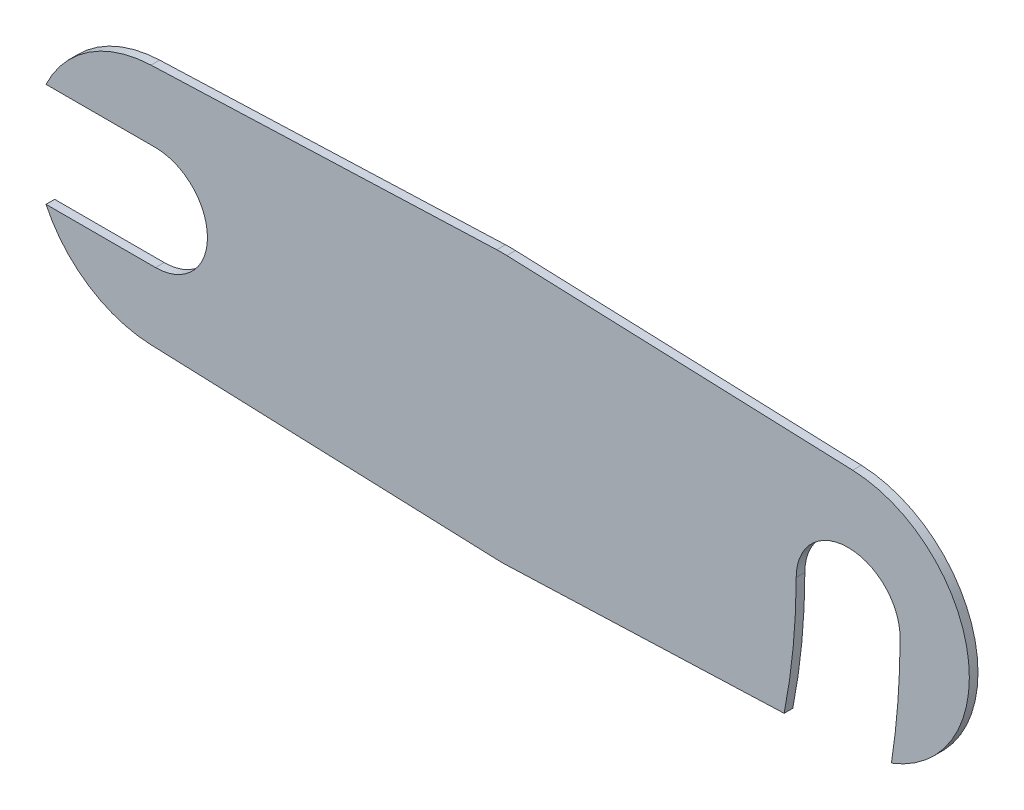
from build123d import *

# Parameters (mm, degrees)
SZKIC1_R                    = 3
DODANIE_WYCI_GNI_CIE1_DEPTH = 0.5
WYTNIJ_WYCI_GNI_CIE1_DEPTH  = 1.5
WYTNIJ_WYCI_GNI_CIE3_DEPTH  = 1.5


with BuildPart() as part:
    # Szkic1 → Dodanie-wyciągnięcie1 (new body)
    with BuildSketch(Plane.XY):
        with BuildLine():
            Line((-0.290625, 7.744548864), (-20.2625, 6.995076393))
            ThreePointArc((-20.2625, 6.995076393), (-27, 0), (-20.2625, -6.995076393))
            Line((-20.2625, -6.995076393), (-0.290625, -7.744548864))
            ThreePointArc((-0.290625, -7.744548864), (0, -7.75), (0.290625, -7.744548864))
            Line((0.290625, -7.744548864), (20.2625, -6.995076393))
            ThreePointArc((20.2625, -6.995076393), (27, 0), (20.2625, 6.995076393))
            Line((20.2625, 6.995076393), (0.290625, 7.744548864))
            ThreePointArc((0.290625, 7.744548864), (0, 7.75), (-0.290625, 7.744548864))
        make_face()
        with Locations((-20, 0)):
            Circle(SZKIC1_R, mode=Mode.SUBTRACT)
        with Locations((20, 0)):
            Circle(SZKIC1_R, mode=Mode.SUBTRACT)
    extrude(amount=DODANIE_WYCI_GNI_CIE1_DEPTH)

    # Szkic2 → Wytnij-wyciągnięcie1 (cut, through all)
    with BuildSketch(Plane.XY.offset(0.5)):
        with BuildLine():
            Line((-20, 3), (-26.32455532, 3))
            ThreePointArc((-26.32455532, 3), (-27, 0), (-26.32455532, -3))
            Line((-26.32455532, -3), (-20, -3))
            ThreePointArc((-20, -3), (-23, 0), (-20, 3))
        make_face()
    extrude(amount=-WYTNIJ_WYCI_GNI_CIE1_DEPTH, mode=Mode.SUBTRACT)

    # Szkic3 → Wytnij-wyciągnięcie3 (cut, through all)
    with BuildSketch(Plane.XY.offset(0.5)):
        with BuildLine():
            ThreePointArc((17, 0), (16.825547843, -3.588735998), (16.303836429, -7.143630766))
            Line((16.303836429, -7.143630766), (20.2625, -6.995076393))
            ThreePointArc((20.2625, -6.995076393), (21.400000598, -6.858571158), (22.5, -6.538348415))
            ThreePointArc((22.5, -6.538348415), (22.874817784, -3.278719262), (23, 0))
            ThreePointArc((23, 0), (20, -3), (17, 0))
        make_face()
    extrude(amount=-WYTNIJ_WYCI_GNI_CIE3_DEPTH, mode=Mode.SUBTRACT)


solid = part.part
